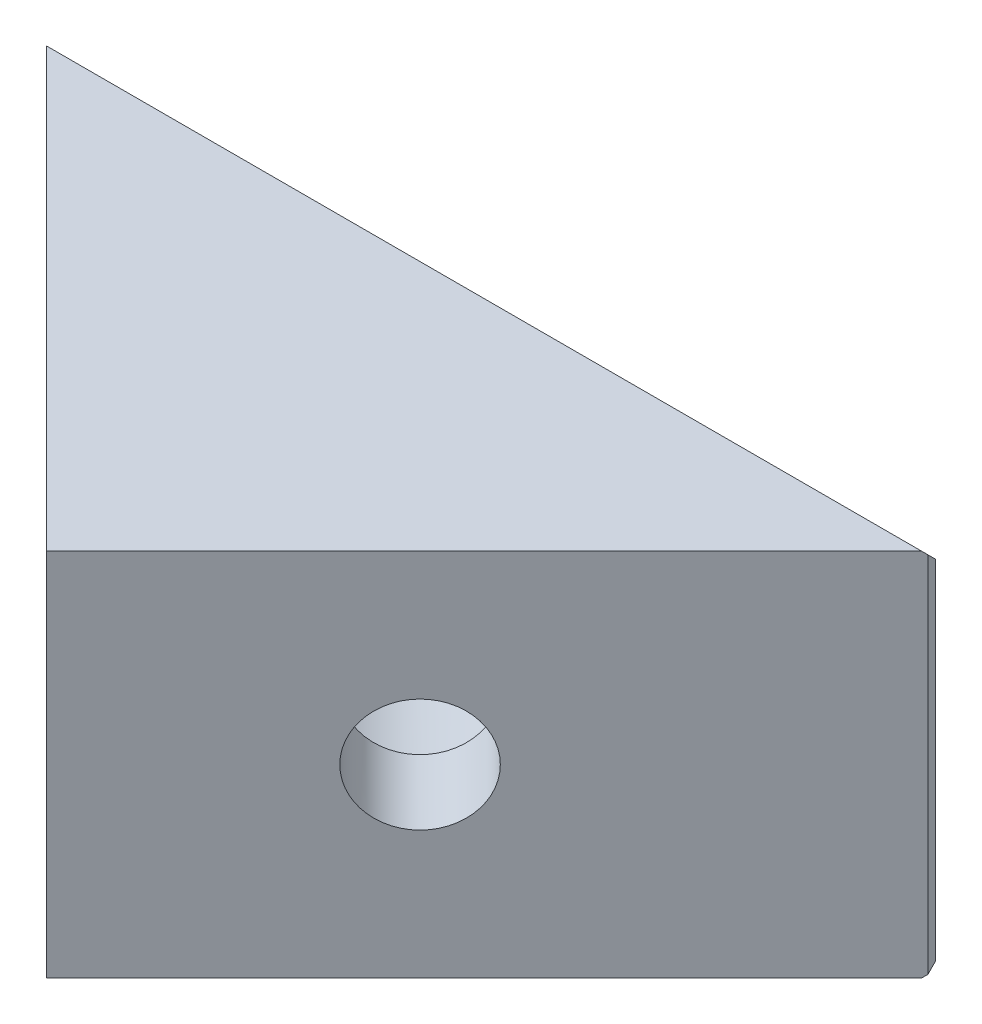
from build123d import *

# Parameters (mm, degrees)
BOSS_EXTRUDE1_DEPTH   = 14
SKETCH2_R             = 2.15
CUT_EXTRUDE1_DEPTH    = 25
CUT_EXTRUDE2_START    = -5.6
SKETCH3_R             = 4.3
CUT_EXTRUDE2_DEPTH    = 19.4
CHAMFER1_SIZE         = 2.1
CHAMFER2_SIZE         = 0.4
CHAMFER2_EDGE_2_SIZE  = 0.4
CHAMFER2_EDGE_3_SIZE2 = 0.4
CHAMFER2_EDGE_3_SIZE  = 0.282842712
CHAMFER2_EDGE_4_SIZE2 = 0.282842712
CHAMFER2_EDGE_4_SIZE  = 0.4
FILLET1_R             = 0.5


with BuildPart() as part:
    # Sketch1 → Boss-Extrude1 (new body)
    with BuildSketch(Plane(origin=(0, 0, 0), x_dir=(1, 0, 0), z_dir=(0, 1, 0))):
        Polygon((0, 0), (33.941125497, 0), (16.970562748, -16.970562748), align=None)
    extrude(amount=BOSS_EXTRUDE1_DEPTH)

    # Sketch2 → Cut-Extrude1 (cut, through all)
    with BuildSketch(Plane(origin=(0, 0, 0), x_dir=(0.707106781, 0, 0.707106781), z_dir=(-0.707106781, 0, 0.707106781))):
        with Locations((14, 7)):
            Circle(SKETCH2_R)
    cut_extrude1 = extrude(amount=-CUT_EXTRUDE1_DEPTH, mode=Mode.SUBTRACT)

    # Sketch3 → Cut-Extrude2 (cut, through all)
    with BuildSketch(Plane(origin=(0, 0, 0), x_dir=(0.707106781, 0, 0.707106781), z_dir=(-0.707106781, 0, 0.707106781)).offset(CUT_EXTRUDE2_START)):
        with Locations((14, 7)):
            Circle(SKETCH3_R)
    cut_extrude2 = extrude(amount=-CUT_EXTRUDE2_DEPTH, mode=Mode.SUBTRACT)

    # Mirror1: Cut-Extrude1, Cut-Extrude2 across plane
    add(cut_extrude1.mirror(Plane(origin=(16.970562748, 0, 0), x_dir=(0, 0, 1), z_dir=(1, 0, 0))), mode=Mode.SUBTRACT)
    add(cut_extrude2.mirror(Plane(origin=(16.970562748, 0, 0), x_dir=(0, 0, 1), z_dir=(1, 0, 0))), mode=Mode.SUBTRACT)

    # Chamfer1
    chamfer1_edges = [part.edges().sort_by_distance(p)[0] for p in [
        (12.339013332, 7, 4.419417382),
        (21.602112165, 7, 4.419417382),
    ]]
    chamfer(chamfer1_edges, length=CHAMFER1_SIZE)

    # Chamfer2
    chamfer2_edges = [part.edges().sort_by_distance(p)[0] for p in [
        (16.970562748, 14, 0),
    ]]
    chamfer(chamfer2_edges, length=CHAMFER2_SIZE)

    # Chamfer2 edge 2
    chamfer2_edge_2_edges = [part.edges().sort_by_distance(p)[0] for p in [
        (16.970562748, 0, 0),
    ]]
    chamfer(chamfer2_edge_2_edges, length=CHAMFER2_EDGE_2_SIZE)

    # Chamfer2 edge 3
    chamfer2_edge_3_edges = [part.edges().sort_by_distance(p)[0] for p in [
        (0, 7, 0),
    ]]
    chamfer(chamfer2_edge_3_edges, length=CHAMFER2_EDGE_3_SIZE, length2=CHAMFER2_EDGE_3_SIZE2)

    # Chamfer2 edge 4
    chamfer2_edge_4_edges = [part.edges().sort_by_distance(p)[0] for p in [
        (33.941125497, 7, 0),
    ]]
    chamfer(chamfer2_edge_4_edges, length=CHAMFER2_EDGE_4_SIZE, length2=CHAMFER2_EDGE_4_SIZE2)

    # Fillet1
    fillet1_edges = [part.edges().sort_by_distance(p)[0] for p in [
        (11.523443743, 3.119120407, 0),
        (22.417681754, 3.119120407, 0),
    ]]
    fillet(fillet1_edges, radius=FILLET1_R)


solid = part.part
